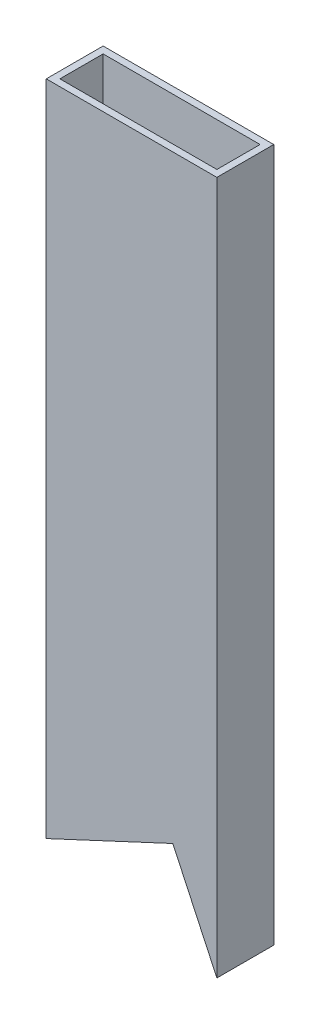
from build123d import *

# Parameters (mm, degrees)
SKETCH1_W           = 76.2
SKETCH1_H           = 25.4
SKETCH1_W_2         = 70.104
SKETCH1_H_2         = 19.304
BOSS_EXTRUDE1_DEPTH = 280
SKETCH3_W           = 76.2
SKETCH3_H           = 25.4
SKETCH3_W_2         = 70.104
SKETCH3_H_2         = 19.304
BOSS_EXTRUDE2_DEPTH = 38.1
CUT_EXTRUDE2_START  = -34.530327
SKETCH5_W           = 25.4
SKETCH5_H           = 76.2
CUT_EXTRUDE2_DEPTH  = 72.630327


with BuildPart() as part:
    # Sketch1 → Boss-Extrude1 (new body)
    with BuildSketch(Plane(origin=(0, 0, 0), x_dir=(1, 0, 0), z_dir=(0, 1, 0))):
        Rectangle(SKETCH1_W, SKETCH1_H)
        Rectangle(SKETCH1_W_2, SKETCH1_H_2, mode=Mode.SUBTRACT)
    extrude(amount=BOSS_EXTRUDE1_DEPTH)

    # Sketch3 → Boss-Extrude2 (add)
    with BuildSketch(Plane(origin=(0, 280, 0), x_dir=(1, 0, 0), z_dir=(0, 1, 0))):
        Rectangle(SKETCH3_W, SKETCH3_H)
        Rectangle(SKETCH3_W_2, SKETCH3_H_2, mode=Mode.SUBTRACT)
    extrude(amount=BOSS_EXTRUDE2_DEPTH)

    # Sketch5 → Cut-Extrude2 (cut)
    with BuildSketch(Plane(origin=(0, 0, 0), x_dir=(0, 0, -1), z_dir=(0.906307787, 0.422618262, 0)).offset(CUT_EXTRUDE2_START)):
        Rectangle(SKETCH5_W, SKETCH5_H)
    extrude(amount=CUT_EXTRUDE2_DEPTH, mode=Mode.SUBTRACT)


solid = part.part
